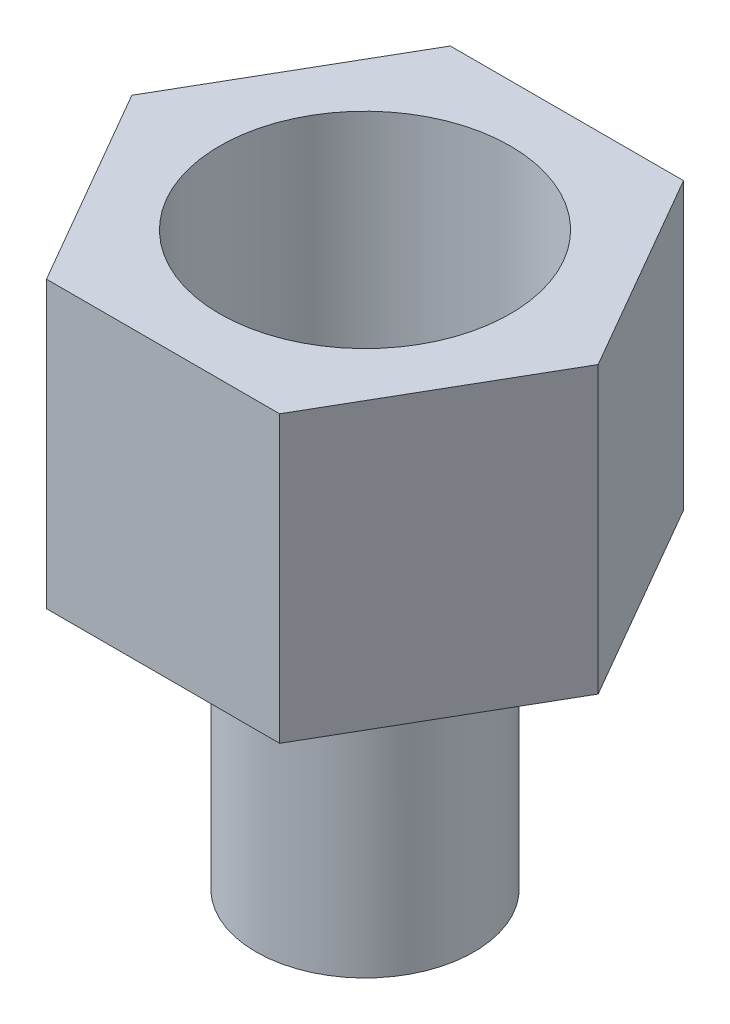
from build123d import *

# Parameters (mm, degrees)
BOSS_EXTRUDE1_DEPTH = 13.462
SKETCH2_R           = 6.858
CUT_EXTRUDE1_DEPTH  = 12.954
SKETCH3_R           = 5.1435
BOSS_EXTRUDE2_DEPTH = 13.462
SKETCH4_R           = 2.794
CUT_EXTRUDE2_DEPTH  = 27.924


with BuildPart() as part:
    # Sketch1 → Boss-Extrude1 (new body)
    with BuildSketch(Plane(origin=(0, 0, 0), x_dir=(1, 0, 0), z_dir=(0, 1, 0))):
        Polygon((5.499261314, 9.525), (-5.499261314, 9.525), (-10.998522628, 0), (-5.499261314, -9.525), (5.499261314, -9.525), (10.998522628, 0), align=None)
    extrude(amount=-BOSS_EXTRUDE1_DEPTH)

    # Sketch2 → Cut-Extrude1 (cut)
    with BuildSketch(Plane(origin=(0, 0, 0), x_dir=(1, 0, 0), z_dir=(0, 1, 0))):
        Circle(SKETCH2_R)
    extrude(amount=-CUT_EXTRUDE1_DEPTH, mode=Mode.SUBTRACT)

    # Sketch3 → Boss-Extrude2 (add)
    with BuildSketch(Plane.XZ.offset(13.462)):
        Circle(SKETCH3_R)
    extrude(amount=BOSS_EXTRUDE2_DEPTH)

    # Sketch4 → Cut-Extrude2 (cut, through all)
    with BuildSketch(Plane.XZ.offset(26.924)):
        Circle(SKETCH4_R)
    extrude(amount=-CUT_EXTRUDE2_DEPTH, mode=Mode.SUBTRACT)


solid = part.part
